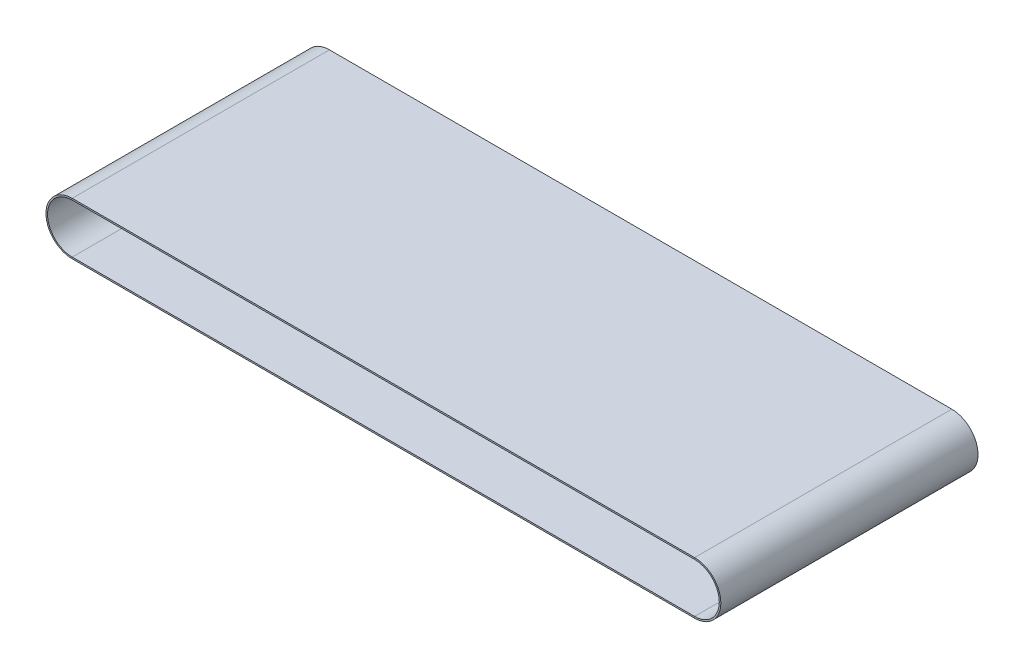
from build123d import *

# Parameters (mm, degrees)
SKETCH4_W = 250
SKETCH4_H = 1.5


with BuildPart() as part:
    # Sweep1: sweep along a path in Sketch2
    with BuildLine(Plane.XY) as sweep1_path:
        Line((0, -24), (-605, -24))
        ThreePointArc((-605, -24), (-629, 0), (-605, 24))
        Line((-605, 24), (0, 24))
        ThreePointArc((0, 24), (24, 0), (0, -24))
    # Sketch4 → Sweep1 (sweep)
    with BuildSketch(Plane(origin=(-605, 0, 0), x_dir=(0, 0, -1), z_dir=(1, 0, 0))):
        with Locations((0, 24.75)):
            Rectangle(SKETCH4_W, SKETCH4_H)
    sweep(path=sweep1_path.line)


solid = part.part
